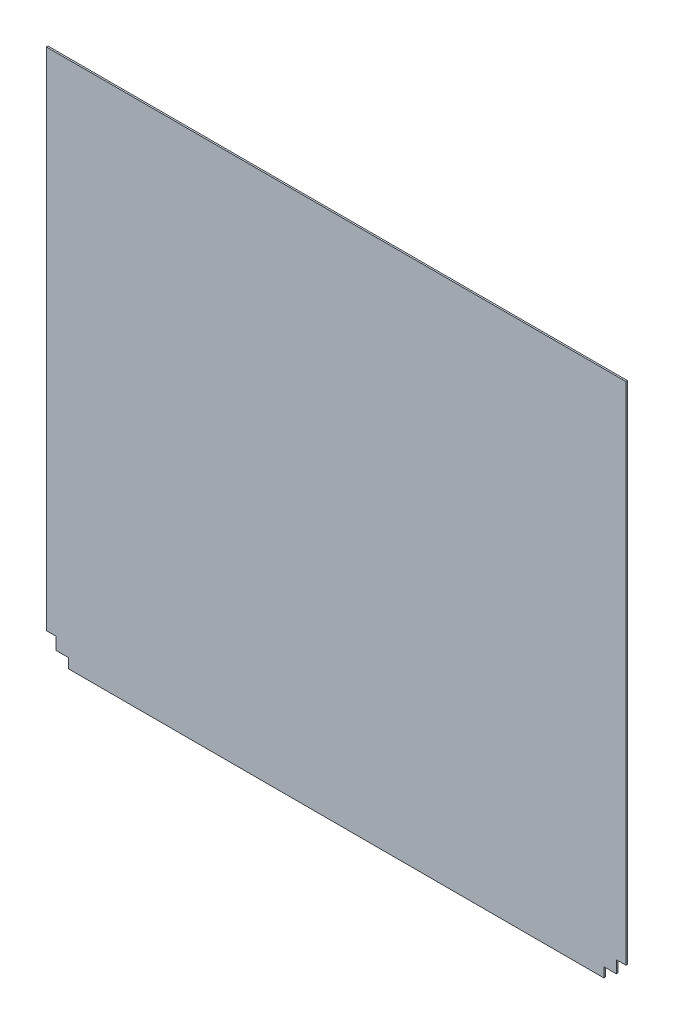
from build123d import *

# Parameters (mm, degrees)
BOSS_EXTRUDE1_DEPTH = 2.54


with BuildPart() as part:
    # Sketch1 → Boss-Extrude1 (new body)
    with BuildSketch(Plane.XY):
        Polygon((0, 825.5), (0, 34.544), (15.24, 34.544), (15.24, 15.24), (34.544, 15.24), (34.544, 0), (872.45698, 0), (872.45698, 15.24), (891.76098, 15.24), (891.76098, 34.544), (907.00098, 34.544), (907.00098, 825.5), align=None)
    extrude(amount=BOSS_EXTRUDE1_DEPTH)


solid = part.part
